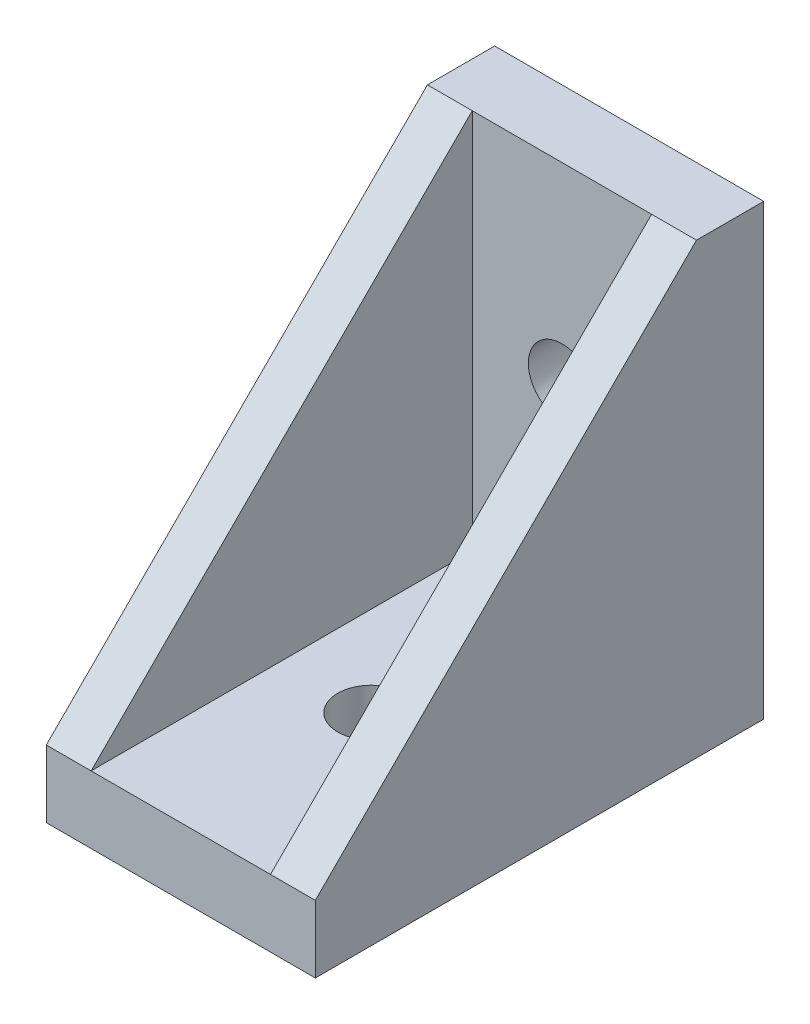
from build123d import *

# Parameters (mm, degrees)
AUFSATZ_LINEAR_AUSTRAGEN1_DEPTH = 6
AUFSATZ_LINEAR_START            = 6
AUFSATZ_LINEAR_AUSTRAGEN4_DEPTH = 2
AUFSATZ_LINEAR_START_2          = -6
AUFSATZ_LINEAR_AUSTRAGEN5_DEPTH = 2
SKIZZE2_R                       = 1.5
SCHNITT_LINEAR_AUSTRAGEN1_DEPTH = 4


with BuildPart() as part:
    # Skizze1 → Aufsatz-Linear austragen1 (new body, symmetric)
    with BuildSketch(Plane(origin=(0, 0, 0), x_dir=(0, 0, -1), z_dir=(1, 0, 0))):
        Polygon((0, 20), (0, 0), (-20, 0), (-20, 3), (-3, 3), (-3, 20), align=None)
    extrude(amount=AUFSATZ_LINEAR_AUSTRAGEN1_DEPTH, both=True)

    # Skizze1_3 → Aufsatz-Linear austragen4 (add)
    with BuildSketch(Plane(origin=(0, 0, 0), x_dir=(0, 0, -1), z_dir=(1, 0, 0)).offset(AUFSATZ_LINEAR_START)):
        Polygon((-3, 3), (-3, 20), (-20, 3), align=None)
    extrude(amount=-AUFSATZ_LINEAR_AUSTRAGEN4_DEPTH)

    # Skizze1_4 → Aufsatz-Linear austragen5 (add)
    with BuildSketch(Plane(origin=(0, 0, 0), x_dir=(0, 0, -1), z_dir=(1, 0, 0)).offset(AUFSATZ_LINEAR_START_2)):
        Polygon((-3, 3), (-3, 20), (-20, 3), align=None)
    extrude(amount=AUFSATZ_LINEAR_AUSTRAGEN5_DEPTH)

    # Skizze2 → Schnitt-Linear austragen1 (cut, through all)
    with BuildSketch(Plane.XY.offset(3)):
        with Locations((0, 11.5)):
            Circle(SKIZZE2_R)
    schnitt_linear_austragen1 = extrude(amount=-SCHNITT_LINEAR_AUSTRAGEN1_DEPTH, mode=Mode.SUBTRACT)

    # Spiegeln2: Schnitt-Linear austragen1 across plane
    add(schnitt_linear_austragen1.mirror(Plane(origin=(0, 0, 0), x_dir=(0, 0.707106781, 0.707106781), z_dir=(0, -0.707106781, 0.707106781))), mode=Mode.SUBTRACT)


solid = part.part
